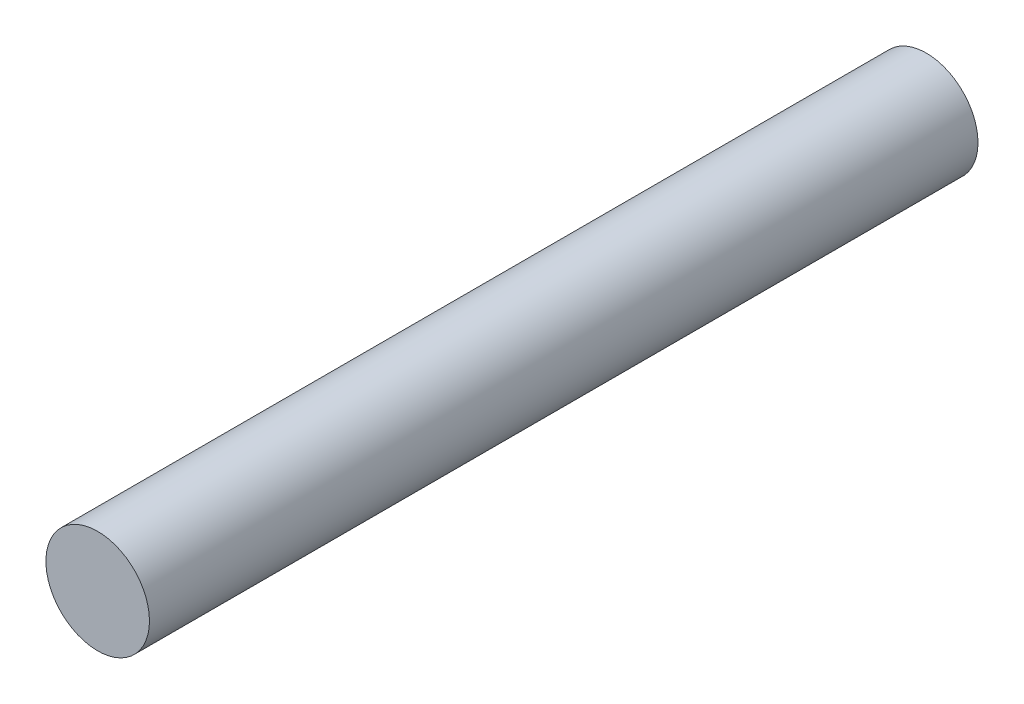
from build123d import *

# Parameters (mm, degrees)
ESQUISSE1_R        = 1.25
BOSS_EXTRU_1_DEPTH = 20


with BuildPart() as part:
    # Esquisse1 → Boss.-Extru.1 (new body)
    with BuildSketch(Plane.XY):
        Circle(ESQUISSE1_R)
    extrude(amount=BOSS_EXTRU_1_DEPTH)


solid = part.part
